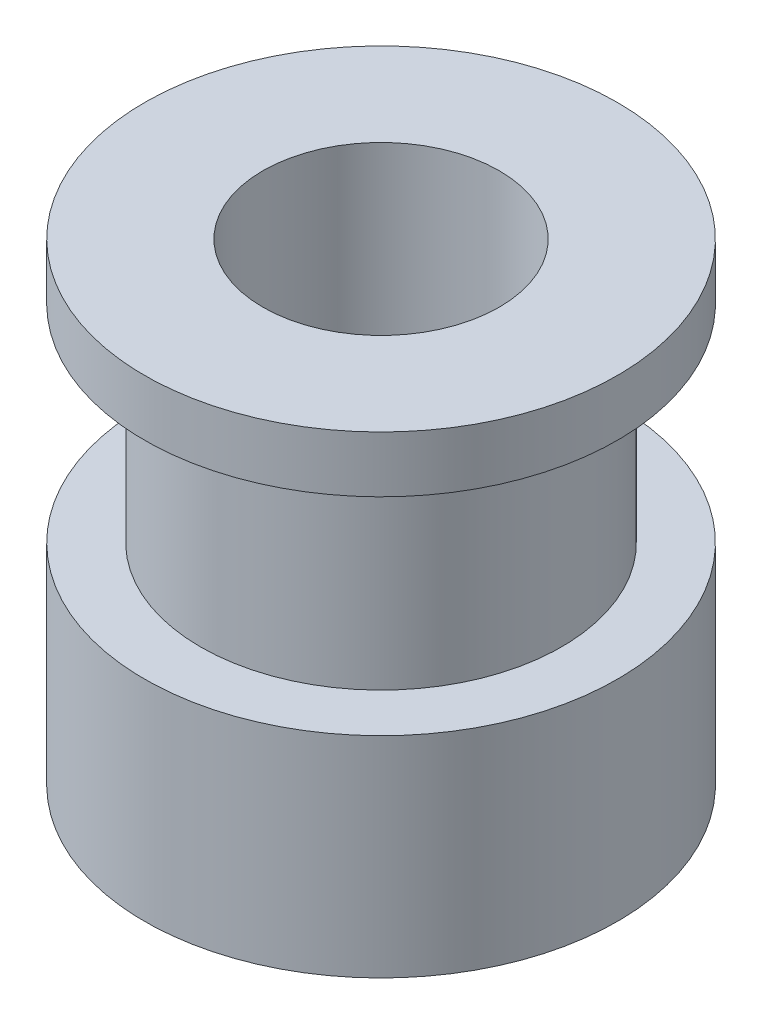
from build123d import *


with BuildPart() as part:
    # Sketch3 → Revolve1 (revolve)
    with BuildSketch(Plane(origin=(0, 0, 0), x_dir=(0, 0, -1), z_dir=(1, 0, 0))):
        Polygon((-4, 0), (-4, 16), (-8, 16), (-8, 14.1), (-6.11, 14.1), (-6.11, 7.1), (-8, 7.1), (-8, 0), align=None)
    revolve(axis=Axis((0, 0, 0), (0, 1, 0)))


solid = part.part
